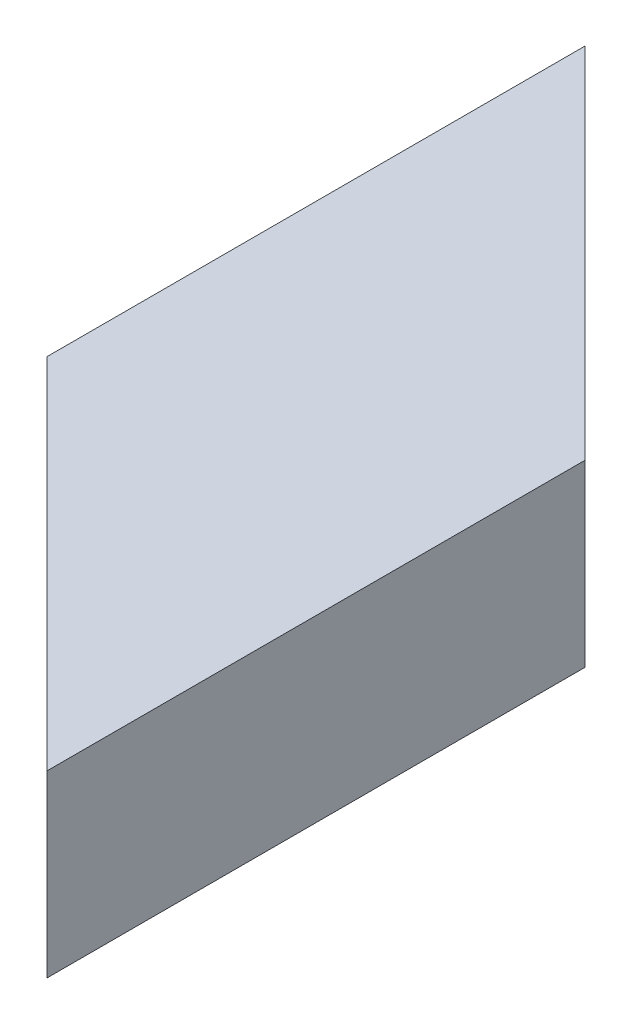
from build123d import *

# Parameters (mm, degrees)
SKETCH1_W           = 50.8
SKETCH1_H           = 25.4
SKETCH1_W_2         = 44.45
SKETCH1_H_2         = 19.05
BOSS_EXTRUDE1_DEPTH = 127
CUT_EXTRUDE1_DEPTH  = 127


with BuildPart() as part:
    # Sketch1 → Boss-Extrude1 (new body)
    with BuildSketch(Plane.XY):
        with Locations((25.4, 12.7)):
            Rectangle(SKETCH1_W, SKETCH1_H)
        with Locations((25.4, 12.7)):
            Rectangle(SKETCH1_W_2, SKETCH1_H_2, mode=Mode.SUBTRACT)
    extrude(amount=BOSS_EXTRUDE1_DEPTH)

    # Sketch2 → Cut-Extrude1 (cut)
    with BuildSketch(Plane(origin=(0, 25.4, 0), x_dir=(1, 0, 0), z_dir=(0, 1, 0))):
        Polygon((0, 0), (50.8, -50.8), (50.8, 0), align=None)
        Polygon((0, -76.2), (0, -127), (50.8, -127), align=None)
    extrude(amount=-CUT_EXTRUDE1_DEPTH, mode=Mode.SUBTRACT)


solid = part.part
